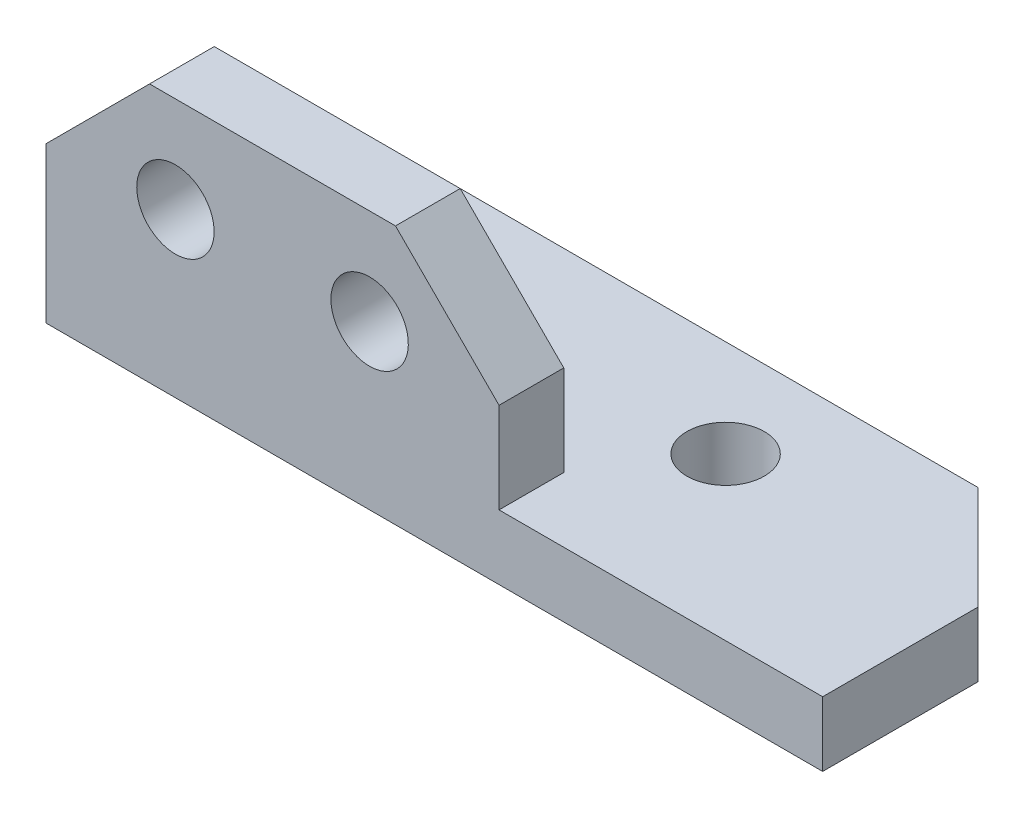
from build123d import *

# Parameters (mm, degrees)
EXTRUDE1_DEPTH                      = 19.05
EXTRUDE1_DEPTH_BACK                 = 19.05
F_6_CLEARANCE_HOLE1_D               = 3.7973
F_6_CLEARANCE_HOLE1_DEPTH           = 6.35
F_6_CLEARANCE_HOLE1_TIP             = 1.140824014
F_6_CLEARANCE_HOLE1_ON_FACE_2_D     = 3.7973
F_6_CLEARANCE_HOLE1_ON_FACE_2_DEPTH = 6.35
F_6_CLEARANCE_HOLE1_ON_FACE_2_TIP   = 1.140824014
SKETCH3_W                           = 15.875
SKETCH3_H                           = 9.525
CUT_EXTRUDE1_DEPTH                  = 24.3313898
CHAMFER1_SIZE                       = 5.08


with BuildPart() as part:
    # Sketch1 → Extrude1 (new, two sides: drawn at the far end of the back side and taken through both)
    with BuildSketch(Plane(origin=(0, 0, 0), x_dir=(0, 0, -1), z_dir=(1, 0, 0)).offset(-EXTRUDE1_DEPTH_BACK)):
        Polygon((-3.175, 9.525), (-3.175, -3.175), (9.525, -3.175), (9.525, 0), (0, 0), (0, 9.525), align=None)
    extrude(amount=EXTRUDE1_DEPTH + EXTRUDE1_DEPTH_BACK)

    # 6 Clearance Hole1
    with Locations(Plane(origin=(6.35, 0, -4.7625), x_dir=(0, 0, 1), z_dir=(0, 1, 0))):
        with Locations((0, 0), (0, -12.7)):
            Hole(F_6_CLEARANCE_HOLE1_D / 2, depth=F_6_CLEARANCE_HOLE1_DEPTH)
            with Locations((0, 0, -(F_6_CLEARANCE_HOLE1_DEPTH + F_6_CLEARANCE_HOLE1_TIP / 2))):  # 118° drill point
                Cone(0, F_6_CLEARANCE_HOLE1_D / 2, F_6_CLEARANCE_HOLE1_TIP, mode=Mode.SUBTRACT)

    # 6 Clearance Hole1 on face 2
    with Locations(Plane(origin=(-12.7, 4.826, 0), x_dir=(-1, 0, 0), z_dir=(0, 0, -1))):
        with Locations((0, 0), (-9.525, 0)):
            Hole(F_6_CLEARANCE_HOLE1_ON_FACE_2_D / 2, depth=F_6_CLEARANCE_HOLE1_ON_FACE_2_DEPTH)
            with Locations((0, 0, -(F_6_CLEARANCE_HOLE1_ON_FACE_2_DEPTH + F_6_CLEARANCE_HOLE1_ON_FACE_2_TIP / 2))):  # 118° drill point
                Cone(0, F_6_CLEARANCE_HOLE1_ON_FACE_2_D / 2, F_6_CLEARANCE_HOLE1_ON_FACE_2_TIP, mode=Mode.SUBTRACT)

    # Sketch3 → Cut-Extrude1 (cut, through all)
    with BuildSketch(Plane(origin=(0, 0, 0), x_dir=(-1, 0, 0), z_dir=(0, 0, -1))):
        with Locations((-11.1125, 4.7625)):
            Rectangle(SKETCH3_W, SKETCH3_H)
    extrude(amount=-CUT_EXTRUDE1_DEPTH, mode=Mode.SUBTRACT)

    # Chamfer1
    chamfer1_edges = [part.edges().sort_by_distance(p)[0] for p in [
        (19.05, -1.5875, -9.525),
        (-19.05, -1.5875, -9.525),
        (-19.05, 9.525, 1.5875),
        (3.175, 9.525, 1.5875),
    ]]
    chamfer(chamfer1_edges, length=CHAMFER1_SIZE)


solid = part.part
